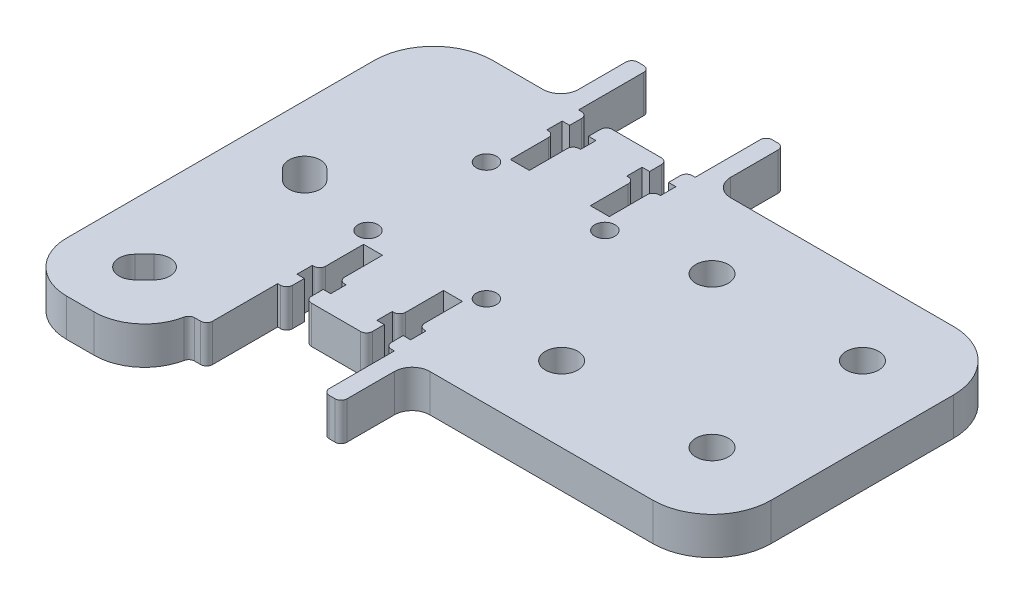
from build123d import *

# Parameters (mm, degrees)
BOSS_EXTRUDE1_DEPTH  = 6.35
FILLET1_R            = 8.5
FILLET2_R            = 10
M5_CLEARANCE_HOLE1_D = 5.5
M3_CLEARANCE_HOLE1_D = 3.4
CUT_EXTRUDE1_DEPTH   = 7.35
SKETCH9_W            = 3
SKETCH9_H            = 12
BOSS_EXTRUDE2_DEPTH  = 6.35
CUT_EXTRUDE2_DEPTH   = 7.35
FILLET3_R            = 1
FILLET4_R            = 3


with BuildPart() as part:
    # Sketch1 → Boss-Extrude1 (new body)
    with BuildSketch(Plane(origin=(0, 0, 0), x_dir=(1, 0, 0), z_dir=(0, 1, 0))):
        Polygon((38.1, -25.4), (-38.1, -25.4), (-38.1, -45.04), (-59.74, -45.04), (-59.74, 25.4), (-38.1, 25.4), (38.1, 25.4), align=None)
    extrude(amount=BOSS_EXTRUDE1_DEPTH)

    # Fillet1
    fillet1_edges = [part.edges().sort_by_distance(p)[0] for p in [
        (-38.1, 3.175, 45.04),
        (-59.74, 3.175, 45.04),
    ]]
    fillet(fillet1_edges, radius=FILLET1_R)

    # Fillet2
    fillet2_edges = [part.edges().sort_by_distance(p)[0] for p in [
        (38.1, 3.175, -25.4),
        (38.1, 3.175, 25.4),
        (-59.74, 3.175, -25.4),
    ]]
    fillet(fillet2_edges, radius=FILLET2_R)

    # M5 Clearance Hole1 (through all)
    with Locations(Plane(origin=(0, 6.35, 0), x_dir=(-1, 0, 0), z_dir=(0, 1, 0))):
        with Locations((0, 12.7), (-25.4, 12.7), (-25.4, -12.7), (0, -12.7)):
            Hole(M5_CLEARANCE_HOLE1_D / 2)

    # M3 Clearance Hole1 (through all)
    with Locations(Plane(origin=(0, 6.35, 0), x_dir=(-1, 0, 0), z_dir=(0, 1, 0))):
        with Locations((15.4, 10), (15.4, -10), (35.4, -10), (35.4, 10)):
            Hole(M3_CLEARANCE_HOLE1_D / 2)

    # Sketch8 → Cut-Extrude1 (cut, through all)
    with BuildSketch(Plane(origin=(0, 6.35, 0), x_dir=(1, 0, 0), z_dir=(0, 1, 0))):
        with BuildLine():
            Line((-51.61383297, -8.23383297), (-49.97383297, -9.87383297))
            ThreePointArc((-49.97383297, -9.87383297), (-46.22616703, -9.87383297), (-46.22616703, -6.12616703))
            Line((-46.22616703, -6.12616703), (-47.86616703, -4.48616703))
            ThreePointArc((-47.86616703, -4.48616703), (-51.61383297, -4.48616703), (-51.61383297, -8.23383297))
        make_face()
        with BuildLine():
            Line((-47.86616703, -36.91383297), (-46.22616703, -35.27383297))
            ThreePointArc((-46.22616703, -35.27383297), (-46.22616703, -31.52616703), (-49.97383297, -31.52616703))
            Line((-49.97383297, -31.52616703), (-51.61383297, -33.16616703))
            ThreePointArc((-51.61383297, -33.16616703), (-51.61383297, -36.91383297), (-47.86616703, -36.91383297))
        make_face()
    extrude(amount=-CUT_EXTRUDE1_DEPTH, mode=Mode.SUBTRACT)

    # Sketch9 → Boss-Extrude2 (add)
    with BuildSketch(Plane(origin=(0, 6.35, 0), x_dir=(1, 0, 0), z_dir=(0, 1, 0))):
        with Locations((-14.05, 31.4)):
            Rectangle(SKETCH9_W, SKETCH9_H)
        with Locations((-36.75, 31.4)):
            Rectangle(SKETCH9_W, SKETCH9_H)
        with Locations((-36.75, -31.4)):
            Rectangle(SKETCH9_W, SKETCH9_H)
        with Locations((-14.05, -31.4)):
            Rectangle(SKETCH9_W, SKETCH9_H)
    extrude(amount=-BOSS_EXTRUDE2_DEPTH)

    # Sketch10 → Cut-Extrude2 (cut, through all)
    with BuildSketch(Plane(origin=(0, 6.35, 0), x_dir=(1, 0, 0), z_dir=(0, 1, 0))):
        Polygon((-33.75, 12.4), (-30.55, 12.4), (-30.55, 19.8), (-29.3, 19.8), (-29.3, 22.4), (-30.55, 22.4), (-30.55, 25.4), (-33.75, 25.4), (-33.75, 22.4), (-35, 22.4), (-35, 19.8), (-33.75, 19.8), align=None)
        Polygon((-20.25, 12.4), (-20.25, 19.8), (-21.5, 19.8), (-21.5, 22.4), (-20.25, 22.4), (-20.25, 25.4), (-17.05, 25.4), (-17.05, 22.4), (-15.8, 22.4), (-15.8, 19.8), (-17.05, 19.8), (-17.05, 12.4), align=None)
        Polygon((-20.25, -22.4), (-20.25, -25.4), (-17.05, -25.4), (-17.05, -22.4), (-15.8, -22.4), (-15.8, -19.8), (-17.05, -19.8), (-17.05, -12.4), (-20.25, -12.4), (-20.25, -19.8), (-21.5, -19.8), (-21.5, -22.4), align=None)
        Polygon((-30.55, -22.4), (-30.55, -25.4), (-33.75, -25.4), (-33.75, -22.4), (-35, -22.4), (-35, -19.8), (-33.75, -19.8), (-33.75, -12.4), (-30.55, -12.4), (-30.55, -19.8), (-29.3, -19.8), (-29.3, -22.4), align=None)
    extrude(amount=-CUT_EXTRUDE2_DEPTH, mode=Mode.SUBTRACT)

    # Fillet3
    fillet3_edges = [part.edges().sort_by_distance(p)[0] for p in [
        (-15.55, 3.175, -37.4),
        (-12.55, 3.175, -37.4),
        (-38.25, 3.175, -37.4),
        (-35.25, 3.175, -37.4),
        (-38.143617795, 3.175, 37.4),
        (-35.25, 3.175, 37.4),
        (-12.55, 3.175, 37.4),
        (-15.55, 3.175, 37.4),
        (-30.55, 3.175, -19.8),
        (-33.75, 3.175, -19.8),
        (-33.75, 3.175, -25.4),
        (-30.55, 3.175, -25.4),
        (-20.25, 3.175, -19.8),
        (-20.25, 3.175, -25.4),
        (-17.05, 3.175, -25.4),
        (-17.05, 3.175, -19.8),
        (-20.25, 3.175, 19.8),
        (-17.05, 3.175, 19.8),
        (-17.05, 3.175, 25.4),
        (-20.25, 3.175, 25.4),
        (-30.55, 3.175, 25.4),
        (-33.75, 3.175, 25.4),
        (-33.75, 3.175, 19.8),
        (-30.55, 3.175, 19.8),
    ]]
    fillet(fillet3_edges, radius=FILLET3_R)

    # Fillet4
    fillet4_edges = [part.edges().sort_by_distance(p)[0] for p in [
        (-12.55, 3.175, -25.4),
        (-38.25, 3.175, -25.4),
        (-12.55, 3.175, 25.4),
    ]]
    fillet(fillet4_edges, radius=FILLET4_R)


solid = part.part
